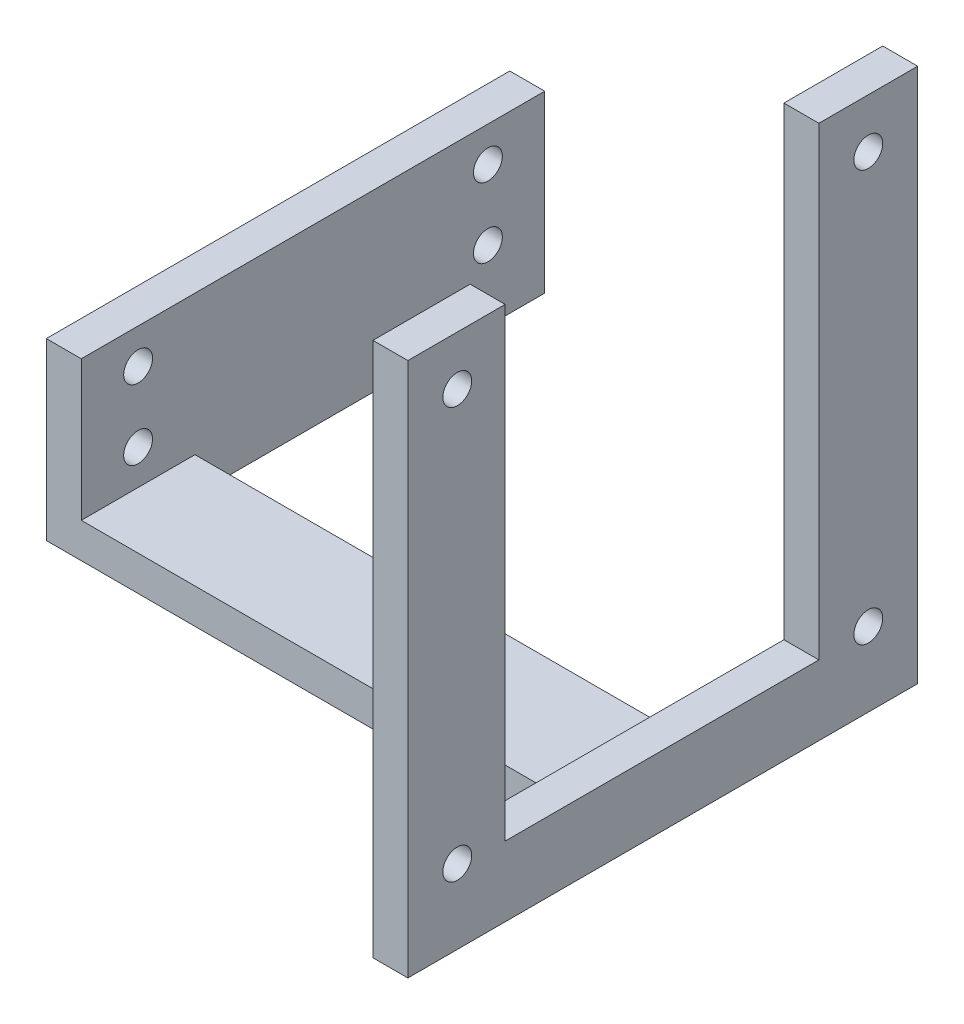
from build123d import *

# Parameters (mm, degrees)
SKETCH1_W            = 13
SKETCH1_H            = 16
BOSS_EXTRUDE1_DEPTH  = 4
SKETCH2_R            = 1.65
CUT_EXTRUDE1_DEPTH   = 10
SKETCH3_W            = 4
SKETCH3_H            = 13
BOSS_EXTRUDE2_DEPTH  = 4
SKETCH4_W            = 13
SKETCH4_H            = 4
BOSS_EXTRUDE3_DEPTH  = 60
SKETCH6_W            = 4
SKETCH6_H            = 21
SKETCH6_H_2          = 13
BOSS_EXTRUDE4_DEPTH  = 28
SKETCH12_W           = 4
SKETCH12_H           = 28
BOSS_EXTRUDE8_DEPTH  = 1.65
SKETCH13_W           = 4
SKETCH13_H           = 28
BOSS_EXTRUDE9_DEPTH  = 1.65
SKETCH14_W           = 4
SKETCH14_H           = 35.878399396
CUT_EXTRUDE5_DEPTH   = 24
SKETCH15_R           = 1.65
CUT_EXTRUDE6_DEPTH   = 24
SKETCH16_W           = 4
SKETCH16_H           = 11.121600604
SKETCH16_H_2         = 11.3
BOSS_EXTRUDE10_DEPTH = 29.15
SKETCH17_R           = 1.65
CUT_EXTRUDE8_DEPTH   = 29.15
SKETCH18_W           = 22.65
SKETCH18_H           = 4
SKETCH18_W_2         = 13
BOSS_EXTRUDE11_DEPTH = 4
SKETCH19_W           = 4
SKETCH19_H           = 20
BOSS_EXTRUDE12_DEPTH = 40
SKETCH20_R           = 1.65
CUT_EXTRUDE9_DEPTH   = 40


with BuildPart() as part:
    # Sketch1 → Boss-Extrude1 (new body)
    with BuildSketch(Plane(origin=(0, 0, 0), x_dir=(0, 0, -1), z_dir=(1, 0, 0))):
        with Locations((6.5, -8)):
            Rectangle(SKETCH1_W, SKETCH1_H)
    extrude(amount=BOSS_EXTRUDE1_DEPTH)

    # Sketch2 → Cut-Extrude1 (cut)
    with BuildSketch(Plane(origin=(4, 0, 0), x_dir=(0, 0, -1), z_dir=(1, 0, 0))):
        with Locations((6.5, -4)):
            Circle(SKETCH2_R)
        with Locations((6.5, -12)):
            Circle(SKETCH2_R)
    extrude(amount=-CUT_EXTRUDE1_DEPTH, mode=Mode.SUBTRACT)

    # Sketch3 → Boss-Extrude2 (add)
    with BuildSketch(Plane.XZ.offset(16)):
        with Locations((2, -6.5)):
            Rectangle(SKETCH3_W, SKETCH3_H)
    extrude(amount=BOSS_EXTRUDE2_DEPTH)

    # Sketch4 → Boss-Extrude3 (add)
    with BuildSketch(Plane(origin=(4, 0, 0), x_dir=(0, 0, -1), z_dir=(1, 0, 0))):
        with Locations((6.5, -18)):
            Rectangle(SKETCH4_W, SKETCH4_H)
    extrude(amount=BOSS_EXTRUDE3_DEPTH)

    # Sketch6 → Boss-Extrude4 (add)
    with BuildSketch(Plane(origin=(0, -16, 0), x_dir=(1, 0, 0), z_dir=(0, 1, 0))):
        with Locations((62, -10.5)):
            Rectangle(SKETCH6_W, SKETCH6_H)
        with Locations((62, 23.5)):
            Rectangle(SKETCH6_W, SKETCH6_H)
        with Locations((62, 6.5)):
            Rectangle(SKETCH6_W, SKETCH6_H_2)
    extrude(amount=BOSS_EXTRUDE4_DEPTH)

    # Sketch12 → Boss-Extrude8 (add)
    with BuildSketch(Plane(origin=(0, 0, -34), x_dir=(-1, 0, 0), z_dir=(0, 0, -1))):
        with Locations((-62, -2)):
            Rectangle(SKETCH12_W, SKETCH12_H)
    extrude(amount=BOSS_EXTRUDE8_DEPTH)

    # Sketch13 → Boss-Extrude9 (add)
    with BuildSketch(Plane.XY.offset(21)):
        with Locations((62, -2)):
            Rectangle(SKETCH13_W, SKETCH13_H)
    extrude(amount=BOSS_EXTRUDE9_DEPTH)

    # Sketch14 → Cut-Extrude5 (cut)
    with BuildSketch(Plane(origin=(0, 12, 0), x_dir=(1, 0, 0), z_dir=(0, 1, 0))):
        with Locations((62, 6.410800302)):
            Rectangle(SKETCH14_W, SKETCH14_H)
    extrude(amount=-CUT_EXTRUDE5_DEPTH, mode=Mode.SUBTRACT)

    # Sketch15 → Cut-Extrude6 (cut)
    with BuildSketch(Plane(origin=(64, 0, 0), x_dir=(0, 0, -1), z_dir=(1, 0, 0))):
        with Locations((-17, -11.5)):
            Circle(SKETCH15_R)
        with Locations((30, -11.5)):
            Circle(SKETCH15_R)
    extrude(amount=-CUT_EXTRUDE6_DEPTH, mode=Mode.SUBTRACT)

    # Sketch16 → Boss-Extrude10 (add)
    with BuildSketch(Plane(origin=(0, 12, 0), x_dir=(1, 0, 0), z_dir=(0, 1, 0))):
        with Locations((62, -17.089199698)):
            Rectangle(SKETCH16_W, SKETCH16_H)
        with Locations((62, 30)):
            Rectangle(SKETCH16_W, SKETCH16_H_2)
    extrude(amount=BOSS_EXTRUDE10_DEPTH)

    # Sketch17 → Cut-Extrude8 (cut)
    with BuildSketch(Plane(origin=(64, 0, 0), x_dir=(0, 0, -1), z_dir=(1, 0, 0))):
        with Locations((-17, 35.5)):
            Circle(SKETCH17_R)
        with Locations((30, 35.5)):
            Circle(SKETCH17_R)
    extrude(amount=-CUT_EXTRUDE8_DEPTH, mode=Mode.SUBTRACT)

    # Sketch18 → Boss-Extrude11 (add)
    with BuildSketch(Plane(origin=(64, 0, 0), x_dir=(0, 0, -1), z_dir=(1, 0, 0))):
        with Locations((-11.325, -18)):
            Rectangle(SKETCH18_W, SKETCH18_H)
        with Locations((24.325, -18)):
            Rectangle(SKETCH18_W, SKETCH18_H)
        with Locations((6.5, -18)):
            Rectangle(SKETCH18_W_2, SKETCH18_H)
    extrude(amount=-BOSS_EXTRUDE11_DEPTH)

    # Sketch19 → Boss-Extrude12 (add)
    with BuildSketch(Plane(origin=(0, 0, -13), x_dir=(-1, 0, 0), z_dir=(0, 0, -1))):
        with Locations((-2, -10)):
            Rectangle(SKETCH19_W, SKETCH19_H)
    extrude(amount=BOSS_EXTRUDE12_DEPTH)

    # Sketch20 → Cut-Extrude9 (cut)
    with BuildSketch(Plane.ZY):
        with Locations((-46.5, -4)):
            Circle(SKETCH20_R)
        with Locations((-46.5, -12)):
            Circle(SKETCH20_R)
    extrude(amount=-CUT_EXTRUDE9_DEPTH, mode=Mode.SUBTRACT)


solid = part.part
